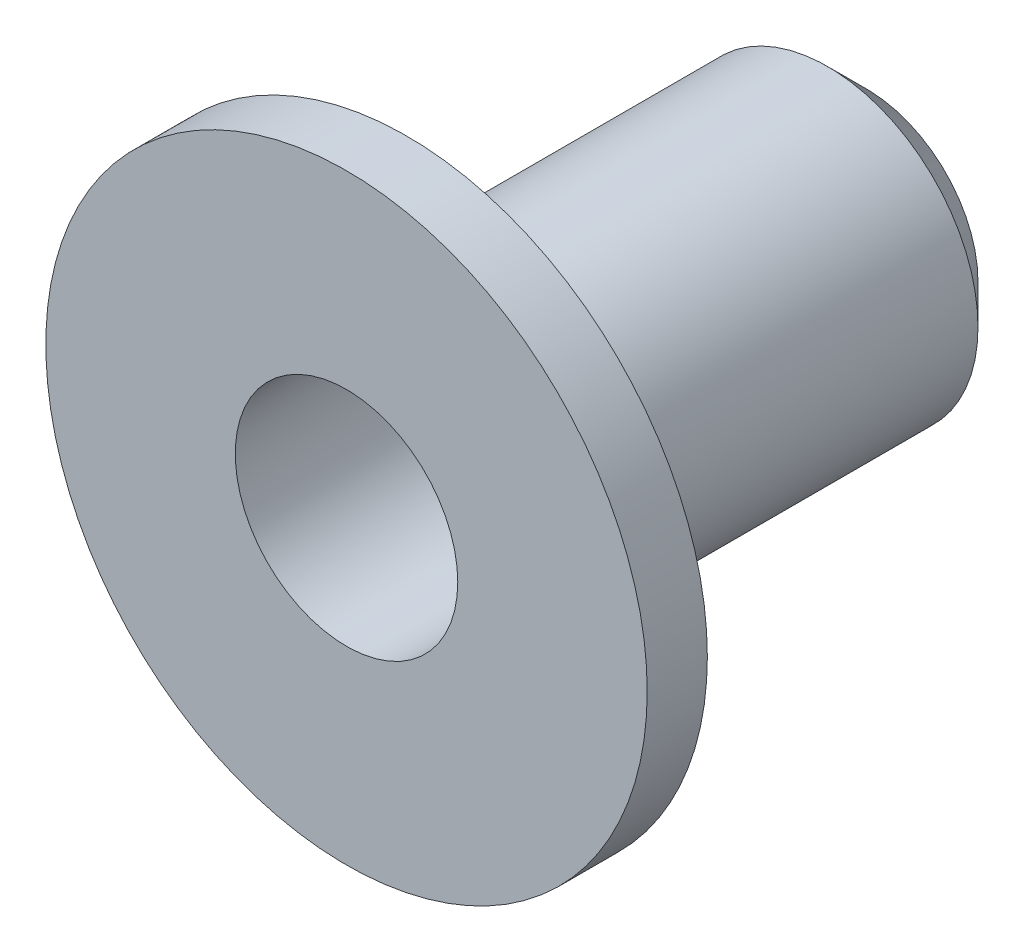
from build123d import *

# Parameters (mm, degrees)
ESQUISSE1_R             = 15
BOSS_EXTRU_1_DEPTH      = 3
ESQUISSE2_R             = 7.5
BOSS_EXTRU_2_DEPTH      = 23
CHANFREIN1_SIZE         = 2
ESQUISSE3_R             = 5.55
ENL_V_MAT_EXTRU_1_DEPTH = 23
ESQUISSE4_R             = 5.55
ENL_V_MAT_EXTRU_2_DEPTH = 26


with BuildPart() as part:
    # Esquisse1 → Boss.-Extru.1 (new body)
    with BuildSketch(Plane.XY):
        Circle(ESQUISSE1_R)
    extrude(amount=BOSS_EXTRU_1_DEPTH)

    # Esquisse2 → Boss.-Extru.2 (add)
    with BuildSketch(Plane(origin=(0, 0, 0), x_dir=(-1, 0, 0), z_dir=(0, 0, -1))):
        Circle(ESQUISSE2_R)
    extrude(amount=BOSS_EXTRU_2_DEPTH)

    # Chanfrein1
    chanfrein1_edges = [part.edges().sort_by_distance(p)[0] for p in [
        (7.5, 0, -23),
    ]]
    chamfer(chanfrein1_edges, length=CHANFREIN1_SIZE)

    # Esquisse3 → Enlèv. mat.-Extru.1 (cut)
    with BuildSketch(Plane(origin=(0, 0, -23), x_dir=(-1, 0, 0), z_dir=(0, 0, -1))):
        Circle(ESQUISSE3_R)
    extrude(amount=-ENL_V_MAT_EXTRU_1_DEPTH, mode=Mode.SUBTRACT)

    # Esquisse4 → Enlèv. mat.-Extru.2 (cut)
    with BuildSketch(Plane.XY.offset(3)):
        Circle(ESQUISSE4_R)
    extrude(amount=-ENL_V_MAT_EXTRU_2_DEPTH, mode=Mode.SUBTRACT)


solid = part.part
